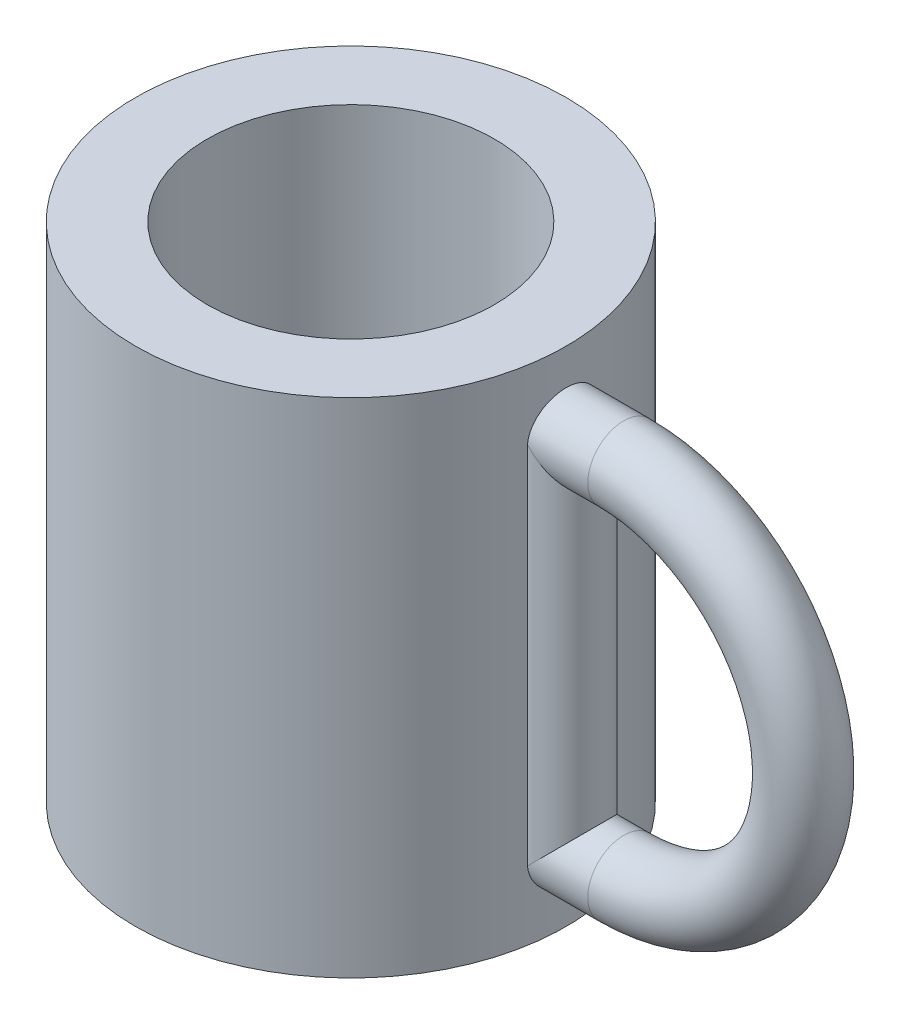
from build123d import *

# Parameters (mm, degrees)
SKETCH1_R           = 15
SKETCH1_R_2         = 10
BOSS_EXTRUDE1_DEPTH = 30
SKETCH2_R           = 15
BOSS_EXTRUDE2_DEPTH = 5
SKETCH7_R           = 2.5


with BuildPart() as part:
    # Sketch1 → Boss-Extrude1 (new body)
    with BuildSketch(Plane(origin=(0, 0, 0), x_dir=(1, 0, 0), z_dir=(0, 1, 0))):
        with Locations(Location((0, 0, 0), (0, 0, 270))):  # turned: the seam where the file's is
            Circle(SKETCH1_R)
        with Locations(Location((0, 0, 0), (0, 0, 270))):  # turned: the seam where the file's is
            Circle(SKETCH1_R_2, mode=Mode.SUBTRACT)
    extrude(amount=BOSS_EXTRUDE1_DEPTH)

    # Sketch2 → Boss-Extrude2 (add)
    with BuildSketch(Plane.XZ):
        with Locations(Location((0, 0, 0), (0, 0, 270))):  # turned: the seam where the file's is
            Circle(SKETCH2_R)
    extrude(amount=BOSS_EXTRUDE2_DEPTH)

    # Sweep6: sweep along a path in Sketch3
    with BuildLine(Plane.XY) as sweep6_path:
        Line((15, 25), (19, 25))
        ThreePointArc((19, 25), (31.5, 12.5), (19, 0))
        Line((19, 0), (15, 0))
        Line((15, 0), (15, 25))
    # Sketch7 → Sweep6 (sweep)
    with BuildSketch(Plane(origin=(15, 0, 0), x_dir=(0, 0, -1), z_dir=(1, 0, 0))):
        with Locations((0, 25)):
            Circle(SKETCH7_R)
    sweep(path=sweep6_path.line, transition=Transition.RIGHT)


solid = part.part
